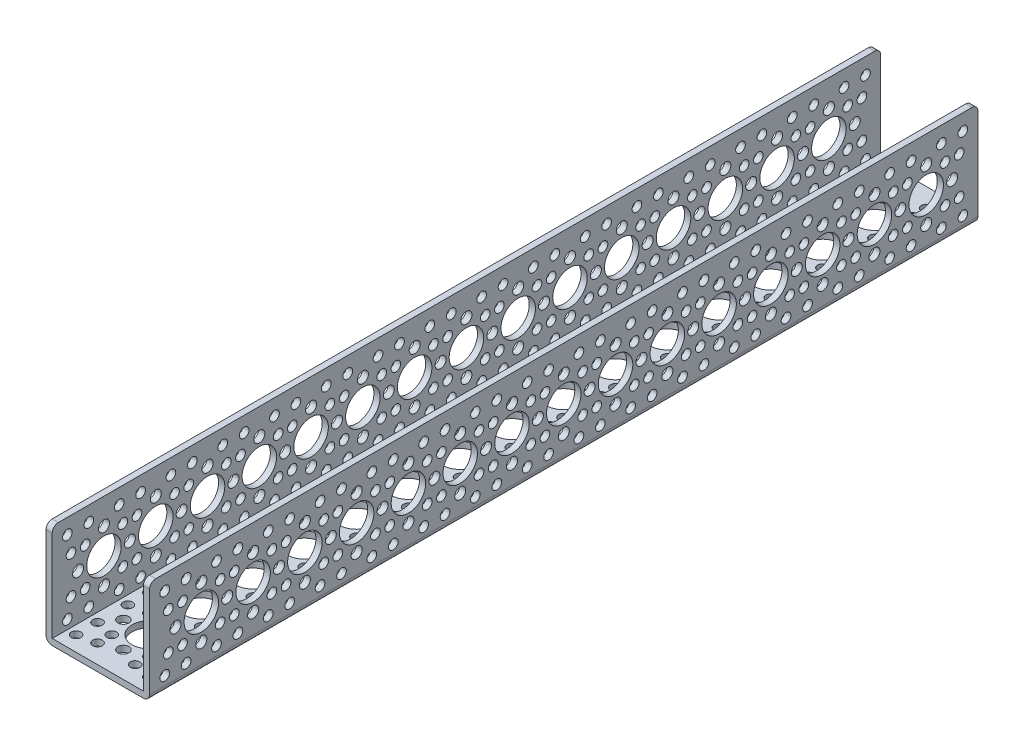
from build123d import *

# Parameters (mm, degrees)
EXTRUDE_THIN1_DEPTH = 304.8
SKETCH3_R           = 6.35
SKETCH3_R_2         = 2.032
SKETCH3_R_3         = 1.778
CUT_EXTRUDE1_DEPTH  = 2.286
SKETCH4_R           = 6.35
SKETCH4_R_2         = 2.032
SKETCH4_R_3         = 1.778
CUT_EXTRUDE2_DEPTH  = 39.1
FILLET1_R           = 2.286


with BuildPart() as part:
    # Sketch1 → Extrude-Thin1 (new body)
    with BuildSketch(Plane.XY):
        Polygon((0, 38.1), (0, 0), (38.1, 0), (38.1, 38.1), (35.814, 38.1), (35.814, 2.286), (2.286, 2.286), (2.286, 38.1), align=None)
    extrude(amount=EXTRUDE_THIN1_DEPTH)

    # Sketch3 → Cut-Extrude1 (cut)
    with BuildSketch(Plane.XZ):
        with Locations((19.05, 19.058384182)):
            Circle(SKETCH3_R)
        with Locations((19.05, 9.533384182)):
            Circle(SKETCH3_R_2)
        with Locations((9.525, 19.058384182)):
            Circle(SKETCH3_R_2)
        with Locations((19.05, 28.583384182)):
            Circle(SKETCH3_R_2)
        with Locations((28.575, 19.058384182)):
            Circle(SKETCH3_R_2)
        with Locations((12.135202787, 25.973181395)):
            Circle(SKETCH3_R_3)
        with Locations((5.579615818, 32.528768363)):
            Circle(SKETCH3_R_3)
        with Locations((25.964797213, 25.973181395)):
            Circle(SKETCH3_R_3)
        with Locations((32.520384182, 32.528768363)):
            Circle(SKETCH3_R_3)
        with Locations((25.964797213, 12.143586968)):
            Circle(SKETCH3_R_3)
        with Locations((32.520384182, 5.588)):
            Circle(SKETCH3_R_3)
        with Locations((12.135202787, 12.143586968)):
            Circle(SKETCH3_R_3)
        with Locations((5.579615818, 5.588)):
            Circle(SKETCH3_R_3)
        with Locations((12.135202787, 31.193586968)):
            Circle(SKETCH3_R_3)
        with Locations((25.964797213, 31.193586968)):
            Circle(SKETCH3_R_3)
        with Locations((25.964797213, 6.923181395)):
            Circle(SKETCH3_R_3)
        with Locations((12.135202787, 6.923181395)):
            Circle(SKETCH3_R_3)
        with Locations((32.520384182, 13.478768363)):
            Circle(SKETCH3_R_3)
        with Locations((5.579615818, 13.478768363)):
            Circle(SKETCH3_R_3)
        with Locations((5.579615818, 24.638)):
            Circle(SKETCH3_R_3)
        with Locations((32.520384182, 24.638)):
            Circle(SKETCH3_R_3)
        with Locations((18.971313238, 38.108384182)):
            Circle(SKETCH3_R)
        with Locations((9.446313238, 38.108384182)):
            Circle(SKETCH3_R_2)
        with Locations((28.496313238, 38.108384182)):
            Circle(SKETCH3_R_2)
        with Locations((18.971313238, 57.158384182)):
            Circle(SKETCH3_R)
        with Locations((18.971313238, 47.633384182)):
            Circle(SKETCH3_R_2)
        with Locations((9.446313238, 57.158384182)):
            Circle(SKETCH3_R_2)
        with Locations((18.971313238, 66.683384182)):
            Circle(SKETCH3_R_2)
        with Locations((28.496313238, 57.158384182)):
            Circle(SKETCH3_R_2)
        with Locations((12.056516025, 64.073181395)):
            Circle(SKETCH3_R_3)
        with Locations((5.500929056, 70.628768363)):
            Circle(SKETCH3_R_3)
        with Locations((25.886110451, 64.073181395)):
            Circle(SKETCH3_R_3)
        with Locations((32.441697419, 70.628768363)):
            Circle(SKETCH3_R_3)
        with Locations((25.886110451, 50.243586968)):
            Circle(SKETCH3_R_3)
        with Locations((32.441697419, 43.688)):
            Circle(SKETCH3_R_3)
        with Locations((12.056516025, 50.243586968)):
            Circle(SKETCH3_R_3)
        with Locations((5.500929056, 43.688)):
            Circle(SKETCH3_R_3)
        with Locations((12.056516025, 69.293586968)):
            Circle(SKETCH3_R_3)
        with Locations((25.886110451, 69.293586968)):
            Circle(SKETCH3_R_3)
        with Locations((25.886110451, 45.023181395)):
            Circle(SKETCH3_R_3)
        with Locations((12.056516025, 45.023181395)):
            Circle(SKETCH3_R_3)
        with Locations((32.441697419, 51.578768363)):
            Circle(SKETCH3_R_3)
        with Locations((5.500929056, 51.578768363)):
            Circle(SKETCH3_R_3)
        with Locations((5.500929056, 62.738)):
            Circle(SKETCH3_R_3)
        with Locations((32.441697419, 62.738)):
            Circle(SKETCH3_R_3)
        with Locations((18.971313238, 76.208384182)):
            Circle(SKETCH3_R)
        with Locations((9.446313238, 76.208384182)):
            Circle(SKETCH3_R_2)
        with Locations((28.496313238, 76.208384182)):
            Circle(SKETCH3_R_2)
        with Locations((18.971313238, 95.258384182)):
            Circle(SKETCH3_R)
        with Locations((18.971313238, 85.733384182)):
            Circle(SKETCH3_R_2)
        with Locations((9.446313238, 95.258384182)):
            Circle(SKETCH3_R_2)
        with Locations((18.971313238, 104.783384182)):
            Circle(SKETCH3_R_2)
        with Locations((28.496313238, 95.258384182)):
            Circle(SKETCH3_R_2)
        with Locations((12.056516025, 102.173181395)):
            Circle(SKETCH3_R_3)
        with Locations((5.500929056, 108.728768363)):
            Circle(SKETCH3_R_3)
        with Locations((25.886110451, 102.173181395)):
            Circle(SKETCH3_R_3)
        with Locations((32.441697419, 108.728768363)):
            Circle(SKETCH3_R_3)
        with Locations((25.886110451, 88.343586968)):
            Circle(SKETCH3_R_3)
        with Locations((32.441697419, 81.788)):
            Circle(SKETCH3_R_3)
        with Locations((12.056516025, 88.343586968)):
            Circle(SKETCH3_R_3)
        with Locations((5.500929056, 81.788)):
            Circle(SKETCH3_R_3)
        with Locations((12.056516025, 107.393586968)):
            Circle(SKETCH3_R_3)
        with Locations((25.886110451, 107.393586968)):
            Circle(SKETCH3_R_3)
        with Locations((25.886110451, 83.123181395)):
            Circle(SKETCH3_R_3)
        with Locations((12.056516025, 83.123181395)):
            Circle(SKETCH3_R_3)
        with Locations((32.441697419, 89.678768363)):
            Circle(SKETCH3_R_3)
        with Locations((5.500929056, 89.678768363)):
            Circle(SKETCH3_R_3)
        with Locations((5.500929056, 100.838)):
            Circle(SKETCH3_R_3)
        with Locations((32.441697419, 100.838)):
            Circle(SKETCH3_R_3)
        with Locations((18.971313238, 133.358384182)):
            Circle(SKETCH3_R)
        with Locations((18.971313238, 123.833384182)):
            Circle(SKETCH3_R_2)
        with Locations((9.446313238, 133.358384182)):
            Circle(SKETCH3_R_2)
        with Locations((18.971313238, 142.883384182)):
            Circle(SKETCH3_R_2)
        with Locations((28.496313238, 133.358384182)):
            Circle(SKETCH3_R_2)
        with Locations((12.056516025, 140.273181395)):
            Circle(SKETCH3_R_3)
        with Locations((5.500929056, 146.828768363)):
            Circle(SKETCH3_R_3)
        with Locations((25.886110451, 140.273181395)):
            Circle(SKETCH3_R_3)
        with Locations((32.441697419, 146.828768363)):
            Circle(SKETCH3_R_3)
        with Locations((25.886110451, 126.443586968)):
            Circle(SKETCH3_R_3)
        with Locations((32.441697419, 119.888)):
            Circle(SKETCH3_R_3)
        with Locations((12.056516025, 126.443586968)):
            Circle(SKETCH3_R_3)
        with Locations((5.500929056, 119.888)):
            Circle(SKETCH3_R_3)
        with Locations((12.056516025, 145.493586968)):
            Circle(SKETCH3_R_3)
        with Locations((25.886110451, 145.493586968)):
            Circle(SKETCH3_R_3)
        with Locations((25.886110451, 121.223181395)):
            Circle(SKETCH3_R_3)
        with Locations((12.056516025, 121.223181395)):
            Circle(SKETCH3_R_3)
        with Locations((32.441697419, 127.778768363)):
            Circle(SKETCH3_R_3)
        with Locations((5.500929056, 127.778768363)):
            Circle(SKETCH3_R_3)
        with Locations((5.500929056, 138.938)):
            Circle(SKETCH3_R_3)
        with Locations((32.441697419, 138.938)):
            Circle(SKETCH3_R_3)
        with Locations((18.971313238, 114.308384182)):
            Circle(SKETCH3_R)
        with Locations((9.446313238, 114.308384182)):
            Circle(SKETCH3_R_2)
        with Locations((28.496313238, 114.308384182)):
            Circle(SKETCH3_R_2)
        with Locations((18.971313238, 152.408384182)):
            Circle(SKETCH3_R)
        with Locations((9.446313238, 152.408384182)):
            Circle(SKETCH3_R_2)
        with Locations((28.496313238, 152.408384182)):
            Circle(SKETCH3_R_2)
        with Locations((18.971313238, 171.458384182)):
            Circle(SKETCH3_R)
        with Locations((18.971313238, 161.933384182)):
            Circle(SKETCH3_R_2)
        with Locations((9.446313238, 171.458384182)):
            Circle(SKETCH3_R_2)
        with Locations((18.971313238, 180.983384182)):
            Circle(SKETCH3_R_2)
        with Locations((28.496313238, 171.458384182)):
            Circle(SKETCH3_R_2)
        with Locations((12.056516025, 178.373181395)):
            Circle(SKETCH3_R_3)
        with Locations((5.500929056, 184.928768363)):
            Circle(SKETCH3_R_3)
        with Locations((25.886110451, 178.373181395)):
            Circle(SKETCH3_R_3)
        with Locations((32.441697419, 184.928768363)):
            Circle(SKETCH3_R_3)
        with Locations((25.886110451, 164.543586968)):
            Circle(SKETCH3_R_3)
        with Locations((32.441697419, 157.988)):
            Circle(SKETCH3_R_3)
        with Locations((12.056516025, 164.543586968)):
            Circle(SKETCH3_R_3)
        with Locations((5.500929056, 157.988)):
            Circle(SKETCH3_R_3)
        with Locations((12.056516025, 183.593586968)):
            Circle(SKETCH3_R_3)
        with Locations((25.886110451, 183.593586968)):
            Circle(SKETCH3_R_3)
        with Locations((25.886110451, 159.323181395)):
            Circle(SKETCH3_R_3)
        with Locations((12.056516025, 159.323181395)):
            Circle(SKETCH3_R_3)
        with Locations((32.441697419, 165.878768363)):
            Circle(SKETCH3_R_3)
        with Locations((5.500929056, 165.878768363)):
            Circle(SKETCH3_R_3)
        with Locations((5.500929056, 177.038)):
            Circle(SKETCH3_R_3)
        with Locations((32.441697419, 177.038)):
            Circle(SKETCH3_R_3)
        with Locations((18.971313238, 209.558384182)):
            Circle(SKETCH3_R)
        with Locations((18.971313238, 200.033384182)):
            Circle(SKETCH3_R_2)
        with Locations((9.446313238, 209.558384182)):
            Circle(SKETCH3_R_2)
        with Locations((18.971313238, 219.083384182)):
            Circle(SKETCH3_R_2)
        with Locations((28.496313238, 209.558384182)):
            Circle(SKETCH3_R_2)
        with Locations((12.056516025, 216.473181395)):
            Circle(SKETCH3_R_3)
        with Locations((5.500929056, 223.028768363)):
            Circle(SKETCH3_R_3)
        with Locations((25.886110451, 216.473181395)):
            Circle(SKETCH3_R_3)
        with Locations((32.441697419, 223.028768363)):
            Circle(SKETCH3_R_3)
        with Locations((25.886110451, 202.643586968)):
            Circle(SKETCH3_R_3)
        with Locations((32.441697419, 196.088)):
            Circle(SKETCH3_R_3)
        with Locations((12.056516025, 202.643586968)):
            Circle(SKETCH3_R_3)
        with Locations((5.500929056, 196.088)):
            Circle(SKETCH3_R_3)
        with Locations((12.056516025, 221.693586968)):
            Circle(SKETCH3_R_3)
        with Locations((25.886110451, 221.693586968)):
            Circle(SKETCH3_R_3)
        with Locations((25.886110451, 197.423181395)):
            Circle(SKETCH3_R_3)
        with Locations((12.056516025, 197.423181395)):
            Circle(SKETCH3_R_3)
        with Locations((32.441697419, 203.978768363)):
            Circle(SKETCH3_R_3)
        with Locations((5.500929056, 203.978768363)):
            Circle(SKETCH3_R_3)
        with Locations((5.500929056, 215.138)):
            Circle(SKETCH3_R_3)
        with Locations((32.441697419, 215.138)):
            Circle(SKETCH3_R_3)
        with Locations((18.971313238, 190.508384182)):
            Circle(SKETCH3_R)
        with Locations((9.446313238, 190.508384182)):
            Circle(SKETCH3_R_2)
        with Locations((28.496313238, 190.508384182)):
            Circle(SKETCH3_R_2)
        with Locations((18.971313238, 228.608384182)):
            Circle(SKETCH3_R)
        with Locations((9.446313238, 228.608384182)):
            Circle(SKETCH3_R_2)
        with Locations((28.496313238, 228.608384182)):
            Circle(SKETCH3_R_2)
        with Locations((18.971313238, 285.758384182)):
            Circle(SKETCH3_R)
        with Locations((18.971313238, 276.233384182)):
            Circle(SKETCH3_R_2)
        with Locations((9.446313238, 285.758384182)):
            Circle(SKETCH3_R_2)
        with Locations((18.971313238, 295.283384182)):
            Circle(SKETCH3_R_2)
        with Locations((28.496313238, 285.758384182)):
            Circle(SKETCH3_R_2)
        with Locations((12.056516025, 292.673181395)):
            Circle(SKETCH3_R_3)
        with Locations((5.500929056, 299.228768363)):
            Circle(SKETCH3_R_3)
        with Locations((25.886110451, 292.673181395)):
            Circle(SKETCH3_R_3)
        with Locations((32.441697419, 299.228768363)):
            Circle(SKETCH3_R_3)
        with Locations((25.886110451, 278.843586968)):
            Circle(SKETCH3_R_3)
        with Locations((32.441697419, 272.288)):
            Circle(SKETCH3_R_3)
        with Locations((12.056516025, 278.843586968)):
            Circle(SKETCH3_R_3)
        with Locations((5.500929056, 272.288)):
            Circle(SKETCH3_R_3)
        with Locations((12.056516025, 297.893586968)):
            Circle(SKETCH3_R_3)
        with Locations((25.886110451, 297.893586968)):
            Circle(SKETCH3_R_3)
        with Locations((25.886110451, 273.623181395)):
            Circle(SKETCH3_R_3)
        with Locations((12.056516025, 273.623181395)):
            Circle(SKETCH3_R_3)
        with Locations((32.441697419, 280.178768363)):
            Circle(SKETCH3_R_3)
        with Locations((5.500929056, 280.178768363)):
            Circle(SKETCH3_R_3)
        with Locations((5.500929056, 291.338)):
            Circle(SKETCH3_R_3)
        with Locations((32.441697419, 291.338)):
            Circle(SKETCH3_R_3)
        with Locations((18.971313238, 247.658384182)):
            Circle(SKETCH3_R)
        with Locations((18.971313238, 238.133384182)):
            Circle(SKETCH3_R_2)
        with Locations((9.446313238, 247.658384182)):
            Circle(SKETCH3_R_2)
        with Locations((18.971313238, 257.183384182)):
            Circle(SKETCH3_R_2)
        with Locations((28.496313238, 247.658384182)):
            Circle(SKETCH3_R_2)
        with Locations((12.056516025, 254.573181395)):
            Circle(SKETCH3_R_3)
        with Locations((5.500929056, 261.128768363)):
            Circle(SKETCH3_R_3)
        with Locations((25.886110451, 254.573181395)):
            Circle(SKETCH3_R_3)
        with Locations((32.441697419, 261.128768363)):
            Circle(SKETCH3_R_3)
        with Locations((25.886110451, 240.743586968)):
            Circle(SKETCH3_R_3)
        with Locations((32.441697419, 234.188)):
            Circle(SKETCH3_R_3)
        with Locations((12.056516025, 240.743586968)):
            Circle(SKETCH3_R_3)
        with Locations((5.500929056, 234.188)):
            Circle(SKETCH3_R_3)
        with Locations((12.056516025, 259.793586968)):
            Circle(SKETCH3_R_3)
        with Locations((25.886110451, 259.793586968)):
            Circle(SKETCH3_R_3)
        with Locations((25.886110451, 235.523181395)):
            Circle(SKETCH3_R_3)
        with Locations((12.056516025, 235.523181395)):
            Circle(SKETCH3_R_3)
        with Locations((32.441697419, 242.078768363)):
            Circle(SKETCH3_R_3)
        with Locations((5.500929056, 242.078768363)):
            Circle(SKETCH3_R_3)
        with Locations((5.500929056, 253.238)):
            Circle(SKETCH3_R_3)
        with Locations((32.441697419, 253.238)):
            Circle(SKETCH3_R_3)
        with Locations((18.971313238, 266.708384182)):
            Circle(SKETCH3_R)
        with Locations((9.446313238, 266.708384182)):
            Circle(SKETCH3_R_2)
        with Locations((28.496313238, 266.708384182)):
            Circle(SKETCH3_R_2)
    extrude(amount=-CUT_EXTRUDE1_DEPTH, mode=Mode.SUBTRACT)

    # Sketch4 → Cut-Extrude2 (cut, through all)
    with BuildSketch(Plane.ZY):
        with Locations((266.7, 19.05)):
            Circle(SKETCH4_R)
        with Locations((266.7, 9.525)):
            Circle(SKETCH4_R_2)
        with Locations((266.7, 28.575)):
            Circle(SKETCH4_R_2)
        with Locations((247.65, 19.05)):
            Circle(SKETCH4_R)
        with Locations((257.174999983, 19.049430852)):
            Circle(SKETCH4_R_2)
        with Locations((247.649430852, 9.525000017)):
            Circle(SKETCH4_R_2)
        with Locations((238.125000017, 19.050569148)):
            Circle(SKETCH4_R_2)
        with Locations((247.650569148, 28.574999983)):
            Circle(SKETCH4_R_2)
        with Locations((240.734789619, 12.13561598)):
            Circle(SKETCH4_R_3)
        with Locations((234.178810945, 5.58042074)):
            Circle(SKETCH4_R_3)
        with Locations((240.73561598, 25.965210381)):
            Circle(SKETCH4_R_3)
        with Locations((234.18042074, 32.521189055)):
            Circle(SKETCH4_R_3)
        with Locations((254.565210381, 25.96438402)):
            Circle(SKETCH4_R_3)
        with Locations((261.121189055, 32.51957926)):
            Circle(SKETCH4_R_3)
        with Locations((254.56438402, 12.134789619)):
            Circle(SKETCH4_R_3)
        with Locations((261.11957926, 5.578810945)):
            Circle(SKETCH4_R_3)
        with Locations((235.514384054, 12.135927915)):
            Circle(SKETCH4_R_3)
        with Locations((235.515210415, 25.965522317)):
            Circle(SKETCH4_R_3)
        with Locations((259.785615946, 25.964072085)):
            Circle(SKETCH4_R_3)
        with Locations((259.784789585, 12.134477683)):
            Circle(SKETCH4_R_3)
        with Locations((253.230420706, 32.520050758)):
            Circle(SKETCH4_R_3)
        with Locations((253.228810911, 5.579282443)):
            Circle(SKETCH4_R_3)
        with Locations((242.069579294, 5.579949242)):
            Circle(SKETCH4_R_3)
        with Locations((242.071189089, 32.520717557)):
            Circle(SKETCH4_R_3)
        with Locations((285.75, 19.05)):
            Circle(SKETCH4_R)
        with Locations((295.275, 19.05)):
            Circle(SKETCH4_R_2)
        with Locations((285.75, 9.525)):
            Circle(SKETCH4_R_2)
        with Locations((276.225, 19.05)):
            Circle(SKETCH4_R_2)
        with Locations((285.75, 28.575)):
            Circle(SKETCH4_R_2)
        with Locations((278.835202787, 12.135202787)):
            Circle(SKETCH4_R_3)
        with Locations((272.279615818, 5.579615818)):
            Circle(SKETCH4_R_3)
        with Locations((278.835202787, 25.964797213)):
            Circle(SKETCH4_R_3)
        with Locations((272.279615818, 32.520384182)):
            Circle(SKETCH4_R_3)
        with Locations((292.664797213, 25.964797213)):
            Circle(SKETCH4_R_3)
        with Locations((299.220384182, 32.520384182)):
            Circle(SKETCH4_R_3)
        with Locations((292.664797213, 12.135202787)):
            Circle(SKETCH4_R_3)
        with Locations((299.220384182, 5.579615818)):
            Circle(SKETCH4_R_3)
        with Locations((273.614797213, 12.135202787)):
            Circle(SKETCH4_R_3)
        with Locations((273.614797213, 25.964797213)):
            Circle(SKETCH4_R_3)
        with Locations((297.885202787, 25.964797213)):
            Circle(SKETCH4_R_3)
        with Locations((297.885202787, 12.135202787)):
            Circle(SKETCH4_R_3)
        with Locations((291.329615818, 32.520384182)):
            Circle(SKETCH4_R_3)
        with Locations((291.329615818, 5.579615818)):
            Circle(SKETCH4_R_3)
        with Locations((280.170384182, 5.579615818)):
            Circle(SKETCH4_R_3)
        with Locations((280.170384182, 32.520384182)):
            Circle(SKETCH4_R_3)
        with Locations((228.600189489, 18.96503245)):
            Circle(SKETCH4_R)
        with Locations((228.600189489, 9.44003245)):
            Circle(SKETCH4_R_2)
        with Locations((228.600189489, 28.49003245)):
            Circle(SKETCH4_R_2)
        with Locations((209.550583913, 18.839064429)):
            Circle(SKETCH4_R)
        with Locations((219.075583896, 18.83849528)):
            Circle(SKETCH4_R_2)
        with Locations((209.550014765, 9.314064446)):
            Circle(SKETCH4_R_2)
        with Locations((200.02558393, 18.839633577)):
            Circle(SKETCH4_R_2)
        with Locations((209.551153061, 28.364064412)):
            Circle(SKETCH4_R_2)
        with Locations((202.635373531, 11.924680408)):
            Circle(SKETCH4_R_3)
        with Locations((196.079394858, 5.369485168)):
            Circle(SKETCH4_R_3)
        with Locations((202.636199893, 25.75427481)):
            Circle(SKETCH4_R_3)
        with Locations((196.081004652, 32.310253483)):
            Circle(SKETCH4_R_3)
        with Locations((216.465794294, 25.753448449)):
            Circle(SKETCH4_R_3)
        with Locations((223.021772968, 32.308643689)):
            Circle(SKETCH4_R_3)
        with Locations((216.464967933, 11.923854047)):
            Circle(SKETCH4_R_3)
        with Locations((223.020163173, 5.367875374)):
            Circle(SKETCH4_R_3)
        with Locations((197.414967967, 11.924992344)):
            Circle(SKETCH4_R_3)
        with Locations((197.415794328, 25.754586746)):
            Circle(SKETCH4_R_3)
        with Locations((221.686199858, 25.753136514)):
            Circle(SKETCH4_R_3)
        with Locations((221.685373497, 11.923542112)):
            Circle(SKETCH4_R_3)
        with Locations((215.131004618, 32.309115187)):
            Circle(SKETCH4_R_3)
        with Locations((215.129394824, 5.368346872)):
            Circle(SKETCH4_R_3)
        with Locations((203.970163207, 5.369013671)):
            Circle(SKETCH4_R_3)
        with Locations((203.971773002, 32.309781986)):
            Circle(SKETCH4_R_3)
        with Locations((38.100568466, 18.795097351)):
            Circle(SKETCH4_R)
        with Locations((38.100568466, 9.270097351)):
            Circle(SKETCH4_R_2)
        with Locations((38.100568466, 28.320097351)):
            Circle(SKETCH4_R_2)
        with Locations((19.050757955, 18.710129801)):
            Circle(SKETCH4_R)
        with Locations((28.575757938, 18.709560653)):
            Circle(SKETCH4_R_2)
        with Locations((19.050188807, 9.185129818)):
            Circle(SKETCH4_R_2)
        with Locations((9.525757972, 18.710698949)):
            Circle(SKETCH4_R_2)
        with Locations((19.051327103, 28.235129784)):
            Circle(SKETCH4_R_2)
        with Locations((12.135547573, 11.795745781)):
            Circle(SKETCH4_R_3)
        with Locations((5.5795689, 5.240550541)):
            Circle(SKETCH4_R_3)
        with Locations((12.136373935, 25.625340183)):
            Circle(SKETCH4_R_3)
        with Locations((5.581178695, 32.181318856)):
            Circle(SKETCH4_R_3)
        with Locations((25.965968336, 25.624513821)):
            Circle(SKETCH4_R_3)
        with Locations((32.52194701, 32.179709061)):
            Circle(SKETCH4_R_3)
        with Locations((25.965141975, 11.79491942)):
            Circle(SKETCH4_R_3)
        with Locations((32.520337215, 5.238940746)):
            Circle(SKETCH4_R_3)
        with Locations((6.915142009, 11.796057716)):
            Circle(SKETCH4_R_3)
        with Locations((6.91596837, 25.625652118)):
            Circle(SKETCH4_R_3)
        with Locations((31.186373901, 25.624201886)):
            Circle(SKETCH4_R_3)
        with Locations((31.185547539, 11.794607484)):
            Circle(SKETCH4_R_3)
        with Locations((24.631178661, 32.180180559)):
            Circle(SKETCH4_R_3)
        with Locations((24.629568866, 5.239412244)):
            Circle(SKETCH4_R_3)
        with Locations((13.470337249, 5.240079043)):
            Circle(SKETCH4_R_3)
        with Locations((13.471947044, 32.180847358)):
            Circle(SKETCH4_R_3)
        with Locations((114.300453441, 18.864118352)):
            Circle(SKETCH4_R)
        with Locations((114.300453441, 9.339118352)):
            Circle(SKETCH4_R_2)
        with Locations((114.300453441, 28.389118352)):
            Circle(SKETCH4_R_2)
        with Locations((76.20064293, 18.779150803)):
            Circle(SKETCH4_R)
        with Locations((76.20064293, 9.254150803)):
            Circle(SKETCH4_R_2)
        with Locations((76.20064293, 28.304150803)):
            Circle(SKETCH4_R_2)
        with Locations((95.250453441, 18.864118352)):
            Circle(SKETCH4_R)
        with Locations((104.775453424, 18.863549204)):
            Circle(SKETCH4_R_2)
        with Locations((95.249884293, 9.339118369)):
            Circle(SKETCH4_R_2)
        with Locations((85.725453458, 18.864687501)):
            Circle(SKETCH4_R_2)
        with Locations((95.251022589, 28.389118335)):
            Circle(SKETCH4_R_2)
        with Locations((88.335243059, 11.949734332)):
            Circle(SKETCH4_R_3)
        with Locations((81.779264386, 5.394539092)):
            Circle(SKETCH4_R_3)
        with Locations((88.336069421, 25.779328734)):
            Circle(SKETCH4_R_3)
        with Locations((81.780874181, 32.335307407)):
            Circle(SKETCH4_R_3)
        with Locations((102.165663822, 25.778502373)):
            Circle(SKETCH4_R_3)
        with Locations((108.721642496, 32.333697613)):
            Circle(SKETCH4_R_3)
        with Locations((102.164837461, 11.948907971)):
            Circle(SKETCH4_R_3)
        with Locations((108.720032701, 5.392929298)):
            Circle(SKETCH4_R_3)
        with Locations((83.114837495, 11.950046268)):
            Circle(SKETCH4_R_3)
        with Locations((83.115663856, 25.779640669)):
            Circle(SKETCH4_R_3)
        with Locations((107.386069387, 25.778190437)):
            Circle(SKETCH4_R_3)
        with Locations((107.385243025, 11.948596036)):
            Circle(SKETCH4_R_3)
        with Locations((100.830874146, 32.334169111)):
            Circle(SKETCH4_R_3)
        with Locations((100.829264352, 5.393400796)):
            Circle(SKETCH4_R_3)
        with Locations((89.670032735, 5.394067594)):
            Circle(SKETCH4_R_3)
        with Locations((89.67164253, 32.334835909)):
            Circle(SKETCH4_R_3)
        with Locations((57.150906882, 18.678236705)):
            Circle(SKETCH4_R)
        with Locations((66.675906865, 18.677667557)):
            Circle(SKETCH4_R_2)
        with Locations((57.150337733, 9.153236722)):
            Circle(SKETCH4_R_2)
        with Locations((47.625906899, 18.678805853)):
            Circle(SKETCH4_R_2)
        with Locations((57.15147603, 28.203236688)):
            Circle(SKETCH4_R_2)
        with Locations((50.2356965, 11.763852685)):
            Circle(SKETCH4_R_3)
        with Locations((43.679717827, 5.208657445)):
            Circle(SKETCH4_R_3)
        with Locations((50.236522861, 25.593447086)):
            Circle(SKETCH4_R_3)
        with Locations((43.681327621, 32.14942576)):
            Circle(SKETCH4_R_3)
        with Locations((64.066117263, 25.592620725)):
            Circle(SKETCH4_R_3)
        with Locations((70.622095936, 32.147815965)):
            Circle(SKETCH4_R_3)
        with Locations((64.065290902, 11.763026323)):
            Circle(SKETCH4_R_3)
        with Locations((70.620486142, 5.20704765)):
            Circle(SKETCH4_R_3)
        with Locations((45.015290936, 11.76416462)):
            Circle(SKETCH4_R_3)
        with Locations((45.016117297, 25.593759022)):
            Circle(SKETCH4_R_3)
        with Locations((69.286522827, 25.59230879)):
            Circle(SKETCH4_R_3)
        with Locations((69.285696466, 11.762714388)):
            Circle(SKETCH4_R_3)
        with Locations((62.731327587, 32.148287463)):
            Circle(SKETCH4_R_3)
        with Locations((62.729717793, 5.207519148)):
            Circle(SKETCH4_R_3)
        with Locations((51.570486176, 5.208185947)):
            Circle(SKETCH4_R_3)
        with Locations((51.57209597, 32.148954262)):
            Circle(SKETCH4_R_3)
        with Locations((171.450583913, 18.839064429)):
            Circle(SKETCH4_R)
        with Locations((180.975583896, 18.83849528)):
            Circle(SKETCH4_R_2)
        with Locations((171.450014765, 9.314064446)):
            Circle(SKETCH4_R_2)
        with Locations((161.92558393, 18.839633577)):
            Circle(SKETCH4_R_2)
        with Locations((171.451153061, 28.364064412)):
            Circle(SKETCH4_R_2)
        with Locations((164.535373531, 11.924680408)):
            Circle(SKETCH4_R_3)
        with Locations((157.979394858, 5.369485168)):
            Circle(SKETCH4_R_3)
        with Locations((164.536199893, 25.75427481)):
            Circle(SKETCH4_R_3)
        with Locations((157.981004652, 32.310253483)):
            Circle(SKETCH4_R_3)
        with Locations((178.365794294, 25.753448449)):
            Circle(SKETCH4_R_3)
        with Locations((184.921772968, 32.308643689)):
            Circle(SKETCH4_R_3)
        with Locations((178.364967933, 11.923854047)):
            Circle(SKETCH4_R_3)
        with Locations((184.920163173, 5.367875374)):
            Circle(SKETCH4_R_3)
        with Locations((159.314967967, 11.924992344)):
            Circle(SKETCH4_R_3)
        with Locations((159.315794328, 25.754586746)):
            Circle(SKETCH4_R_3)
        with Locations((183.586199858, 25.753136514)):
            Circle(SKETCH4_R_3)
        with Locations((183.585373497, 11.923542112)):
            Circle(SKETCH4_R_3)
        with Locations((177.031004618, 32.309115187)):
            Circle(SKETCH4_R_3)
        with Locations((177.029394824, 5.368346872)):
            Circle(SKETCH4_R_3)
        with Locations((165.870163207, 5.369013671)):
            Circle(SKETCH4_R_3)
        with Locations((165.871773002, 32.309781986)):
            Circle(SKETCH4_R_3)
        with Locations((133.351167826, 18.628128857)):
            Circle(SKETCH4_R)
        with Locations((142.876167809, 18.627559709)):
            Circle(SKETCH4_R_2)
        with Locations((133.350598677, 9.103128874)):
            Circle(SKETCH4_R_2)
        with Locations((123.826167843, 18.628698006)):
            Circle(SKETCH4_R_2)
        with Locations((133.351736974, 28.15312884)):
            Circle(SKETCH4_R_2)
        with Locations((126.435957444, 11.713744837)):
            Circle(SKETCH4_R_3)
        with Locations((119.879978771, 5.158549597)):
            Circle(SKETCH4_R_3)
        with Locations((126.436783805, 25.543339239)):
            Circle(SKETCH4_R_3)
        with Locations((119.881588565, 32.099317912)):
            Circle(SKETCH4_R_3)
        with Locations((140.266378207, 25.542512878)):
            Circle(SKETCH4_R_3)
        with Locations((146.82235688, 32.097708118)):
            Circle(SKETCH4_R_3)
        with Locations((140.265551846, 11.712918476)):
            Circle(SKETCH4_R_3)
        with Locations((146.820747086, 5.156939803)):
            Circle(SKETCH4_R_3)
        with Locations((121.21555188, 11.714056773)):
            Circle(SKETCH4_R_3)
        with Locations((121.216378241, 25.543651174)):
            Circle(SKETCH4_R_3)
        with Locations((145.486783771, 25.542200942)):
            Circle(SKETCH4_R_3)
        with Locations((145.48595741, 11.712606541)):
            Circle(SKETCH4_R_3)
        with Locations((138.931588531, 32.098179616)):
            Circle(SKETCH4_R_3)
        with Locations((138.929978737, 5.157411301)):
            Circle(SKETCH4_R_3)
        with Locations((127.77074712, 5.158078099)):
            Circle(SKETCH4_R_3)
        with Locations((127.772356914, 32.098846414)):
            Circle(SKETCH4_R_3)
        with Locations((152.400773402, 18.754096879)):
            Circle(SKETCH4_R)
        with Locations((152.400773402, 9.229096879)):
            Circle(SKETCH4_R_2)
        with Locations((152.400773402, 28.279096879)):
            Circle(SKETCH4_R_2)
        with Locations((190.500583913, 18.839064429)):
            Circle(SKETCH4_R)
        with Locations((190.500583913, 9.314064429)):
            Circle(SKETCH4_R_2)
        with Locations((190.500583913, 28.364064429)):
            Circle(SKETCH4_R_2)
    extrude(amount=-CUT_EXTRUDE2_DEPTH, mode=Mode.SUBTRACT)

    # Fillet1
    fillet1_edges = [part.edges().sort_by_distance(p)[0] for p in [
        (38.1, 0, 152.4),
        (0, 0, 152.4),
        (36.957, 38.1, 304.8),
        (1.143, 38.1, 304.8),
        (36.957, 38.1, 0),
        (1.143, 38.1, 0),
    ]]
    fillet(fillet1_edges, radius=FILLET1_R)


solid = part.part
